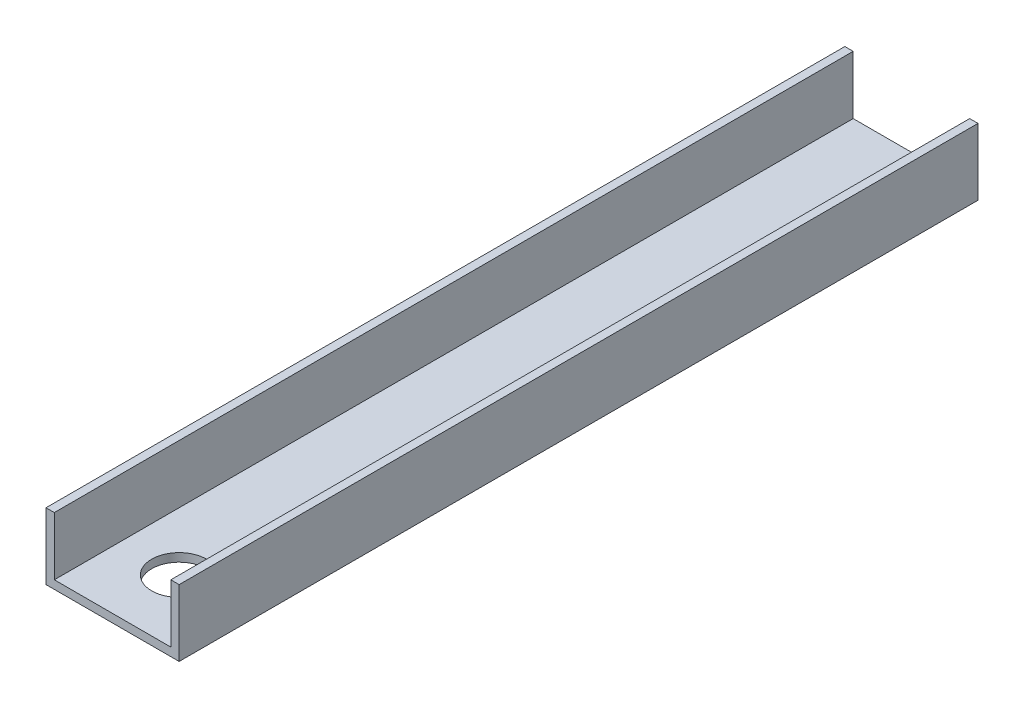
from build123d import *

# Parameters (mm, degrees)
SKETCH1_W           = 50.8
SKETCH1_H           = 25.4
BOSS_EXTRUDE1_DEPTH = 304.8
SKETCH2_W           = 44.45
SKETCH2_H           = 22.225
CUT_EXTRUDE1_DEPTH  = 305.8
SKETCH3_R           = 10.4775
CUT_EXTRUDE2_DEPTH  = 4.175


with BuildPart() as part:
    # Sketch1 → Boss-Extrude1 (new body)
    with BuildSketch(Plane.XY):
        with Locations((25.4, 12.7)):
            Rectangle(SKETCH1_W, SKETCH1_H)
    extrude(amount=BOSS_EXTRUDE1_DEPTH)

    # Sketch2 → Cut-Extrude1 (cut, through all)
    with BuildSketch(Plane(origin=(0, 0, 0), x_dir=(-1, 0, 0), z_dir=(0, 0, -1))):
        with Locations((-25.4, 14.2875)):
            Rectangle(SKETCH2_W, SKETCH2_H)
    extrude(amount=-CUT_EXTRUDE1_DEPTH, mode=Mode.SUBTRACT)

    # Sketch3 → Cut-Extrude2 (cut, through all)
    with BuildSketch(Plane(origin=(0, 3.175, 0), x_dir=(1, 0, 0), z_dir=(0, 1, 0))):
        with Locations((25.4, -279.4)):
            Circle(SKETCH3_R)
    extrude(amount=-CUT_EXTRUDE2_DEPTH, mode=Mode.SUBTRACT)


solid = part.part
